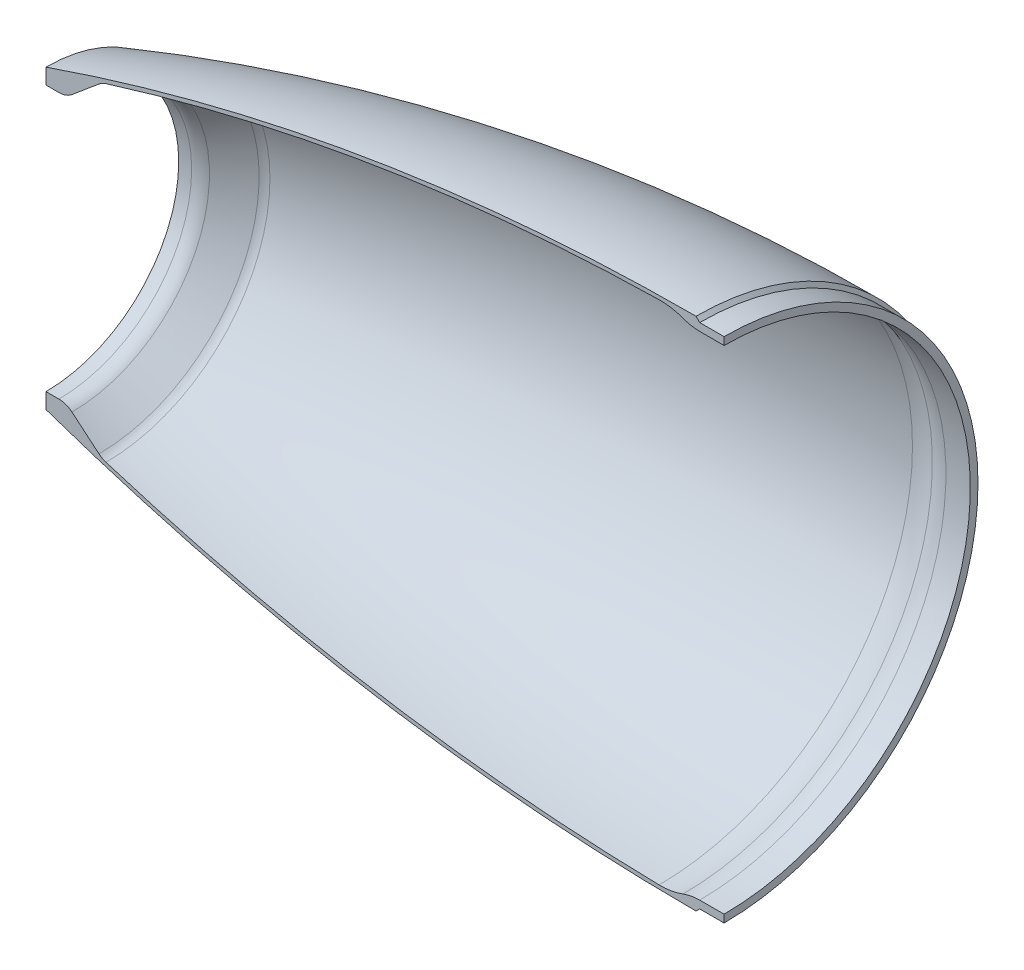
from build123d import *

# Parameters (mm, degrees)
REVOLVE1_ANGLE = 180


with BuildPart() as part:
    # Sketch1 → Revolve1 (revolve)
    with BuildSketch(Plane.XY):
        with BuildLine():
            Line((-203.2, 46.355), (-203.2, 41.4909))
            Line((-203.2, 41.4909), (-199.161210988, 41.4909))
            ThreePointArc((-199.161210988, 41.4909), (-196.989383077, 41.873851858), (-195.079509666, 42.976517786))
            Line((-195.079509666, 42.976517786), (-186.641312326, 50.057006062))
            ThreePointArc((-186.641312326, 50.057006062), (-185.604253506, 50.765114497), (-184.448126603, 51.255297255))
            ThreePointArc((-184.448126603, 51.255297255), (-98.994308497, 71.366370982), (-11.557, 79.210311199))
            ThreePointArc((-11.557, 79.210311199), (-7.739510449, 78.92004648), (-4.044584679, 77.917547785))
            ThreePointArc((-4.044584679, 77.917547785), (-1.493258292, 77.212550225), (1.143, 76.975))
            Line((1.143, 76.975), (8.763, 76.975))
            Line((8.763, 76.975), (8.763, 79.375))
            Line((8.763, 79.375), (1.143, 79.375))
            Line((1.143, 79.375), (0, 80.518))
            ThreePointArc((0, 80.518), (-103.025907626, 71.917734953), (-203.2, 46.355))
        make_face()
    revolve(axis=Axis((0, 0, 0), (-1, 0, 0)), revolution_arc=REVOLVE1_ANGLE)


solid = part.part
